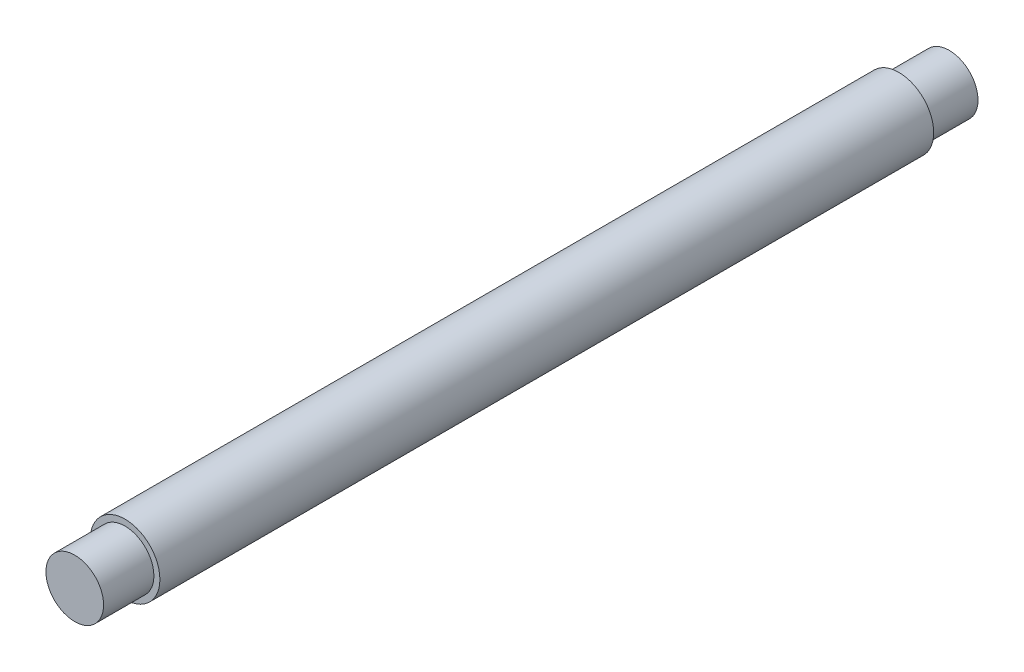
from build123d import *

# Parameters (mm, degrees)
IZIM1_R                     = 14.9
Y_KSEKLIK_EKSTR_ZYON1_DEPTH = 26
IZIM2_R                     = 18
Y_KSEKLIK_EKSTR_ZYON2_DEPTH = 400
IZIM4_R                     = 14.9
Y_KSEKLIK_EKSTR_ZYON3_DEPTH = 26


with BuildPart() as part:
    # Çizim1 → Yükseklik-Ekstrüzyon1 (new body)
    with BuildSketch(Plane.XY):
        Circle(IZIM1_R)
    extrude(amount=Y_KSEKLIK_EKSTR_ZYON1_DEPTH)

    # Çizim2 → Yükseklik-Ekstrüzyon2 (add)
    with BuildSketch(Plane.XY.offset(26)):
        Circle(IZIM2_R)
    extrude(amount=Y_KSEKLIK_EKSTR_ZYON2_DEPTH)

    # Çizim4 → Yükseklik-Ekstrüzyon3 (add)
    with BuildSketch(Plane.XY.offset(426)):
        Circle(IZIM4_R)
    extrude(amount=Y_KSEKLIK_EKSTR_ZYON3_DEPTH)


solid = part.part
